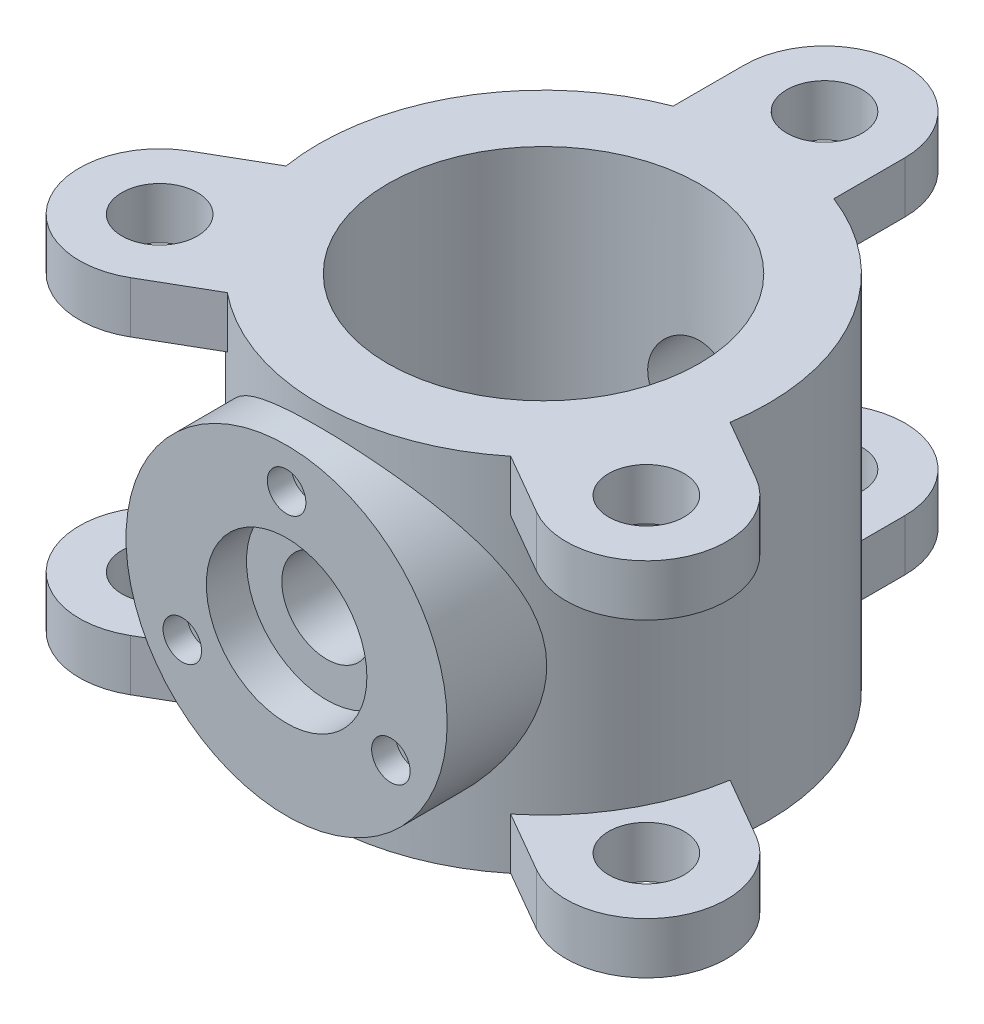
from build123d import *

# Parameters (mm, degrees)
SKETCH2_R               = 140
SKETCH2_R_2             = 97
BOSS_EXTRUDE1_DEPTH     = 225
SKETCH3_R               = 23.5
BOSS_EXTRUDE2_DEPTH     = 32
CIRPATTERN1_COUNT       = 3
MIRROR1_COPY_1_SKETCH_R = 23.5
MIRROR1_COPY_1_DEPTH    = 32
MIRROR1_COPY_2_SKETCH_R = 23.5
MIRROR1_COPY_2_DEPTH    = 32
BOSS_EXTRUDE3_REACH     = 387
SKETCH4_R               = 100
SKETCH6_R               = 50
CUT_EXTRUDE1_DEPTH      = 25
SKETCH7_R               = 28
CUT_EXTRUDE2_DEPTH      = 361
SKETCH8_R               = 12
CUT_EXTRUDE3_DEPTH      = 15
CIRPATTERN2_COUNT       = 3


with BuildPart() as part:
    # Sketch2 → Boss-Extrude1 (new body)
    with BuildSketch(Plane(origin=(0, 0, 0), x_dir=(1, 0, 0), z_dir=(0, 1, 0))):
        Circle(SKETCH2_R)
        Circle(SKETCH2_R_2, mode=Mode.SUBTRACT)
    extrude(amount=BOSS_EXTRUDE1_DEPTH)

    # Sketch3 → Boss-Extrude2 (add)
    with BuildSketch(Plane(origin=(0, 225, 0), x_dir=(1, 0, 0), z_dir=(0, 1, 0))):
        with BuildLine():
            Line((-50, 105), (50, 105))
            Line((50, 105), (50, 175))
            ThreePointArc((50, 175), (0, 225), (-50, 175))
            Line((-50, 175), (-50, 105))
        make_face()
        with Locations((0, 175)):
            Circle(SKETCH3_R, mode=Mode.SUBTRACT)
    boss_extrude2 = extrude(amount=-BOSS_EXTRUDE2_DEPTH)

    # CirPattern1: Boss-Extrude2 ×3 about axis
    cirpattern1_axis = Axis((0, 0, 0), (0, 1, 0))
    for i in range(1, CIRPATTERN1_COUNT):
        add(boss_extrude2.rotate(cirpattern1_axis, i * 360 / CIRPATTERN1_COUNT))

    # Mirror1: Boss-Extrude2 across plane
    add(boss_extrude2.mirror(Plane.ZX.offset(112.5)))

    # Mirror1 copy 1 sketch → Mirror1 copy 1 (add)
    with BuildSketch(Plane(origin=(0, 0, 0), x_dir=(-0.5, 0, -0.866025404), z_dir=(0, -1, 0))):
        with BuildLine():
            Line((-50, -105), (50, -105))
            Line((50, -105), (50, -175))
            ThreePointArc((50, -175), (0, -225), (-50, -175))
            Line((-50, -175), (-50, -105))
        make_face()
        with Locations((0, -175)):
            Circle(MIRROR1_COPY_1_SKETCH_R, mode=Mode.SUBTRACT)
    extrude(amount=-MIRROR1_COPY_1_DEPTH)

    # Mirror1 copy 2 sketch → Mirror1 copy 2 (add)
    with BuildSketch(Plane(origin=(0, 0, 0), x_dir=(-0.5, 0, 0.866025404), z_dir=(0, -1, 0))):
        with BuildLine():
            Line((-50, -105), (50, -105))
            Line((50, -105), (50, -175))
            ThreePointArc((50, -175), (0, -225), (-50, -175))
            Line((-50, -175), (-50, -105))
        make_face()
        with Locations((0, -175)):
            Circle(MIRROR1_COPY_2_SKETCH_R, mode=Mode.SUBTRACT)
    extrude(amount=-MIRROR1_COPY_2_DEPTH)

    # Sketch4 → Boss-Extrude3 (add, up to next)
    with BuildSketch(Plane.XY.offset(160), mode=Mode.PRIVATE) as boss_extrude3_sk1:
        with Locations((0, 112.5)):
            Circle(SKETCH4_R)
    boss_extrude3_tool1 = extrude(boss_extrude3_sk1.sketch, amount=-BOSS_EXTRUDE3_REACH, mode=Mode.PRIVATE) - part.part
    add(boss_extrude3_tool1.solids().sort_by_distance((0, 112.5, 160))[0])

    # Sketch6 → Cut-Extrude1 (cut)
    with BuildSketch(Plane.XY.offset(160)):
        with Locations((0, 112.5)):
            Circle(SKETCH6_R)
    extrude(amount=-CUT_EXTRUDE1_DEPTH, mode=Mode.SUBTRACT)

    # Sketch7 → Cut-Extrude2 (cut, through all)
    with BuildSketch(Plane.XY.offset(135)):
        with Locations((0, 112.5)):
            Circle(SKETCH7_R)
    extrude(amount=-CUT_EXTRUDE2_DEPTH, mode=Mode.SUBTRACT)

    # Sketch8 → Cut-Extrude3 (cut)
    with BuildSketch(Plane.XY.offset(160)):
        with Locations((0, 187.5)):
            Circle(SKETCH8_R)
    cut_extrude3 = extrude(amount=-CUT_EXTRUDE3_DEPTH, mode=Mode.SUBTRACT)

    # CirPattern2: Cut-Extrude3 ×3 about axis
    cirpattern2_axis = Axis((0, 112.5, 0), (0, 0, 1))
    for i in range(1, CIRPATTERN2_COUNT):
        add(cut_extrude3.rotate(cirpattern2_axis, i * 360 / CIRPATTERN2_COUNT), mode=Mode.SUBTRACT)


solid = part.part
